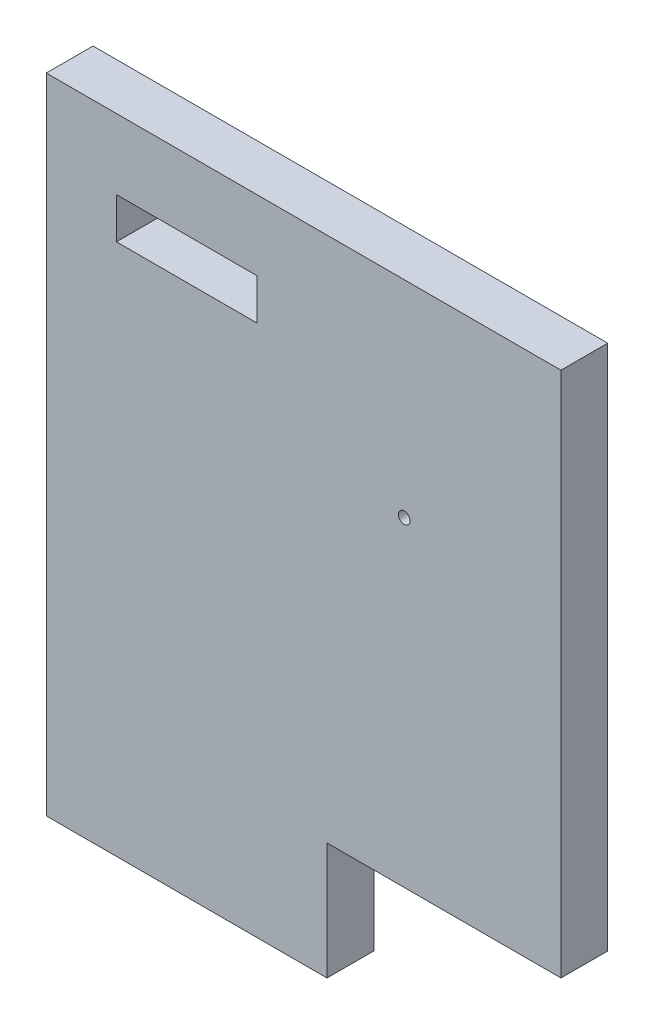
from build123d import *

# Parameters (mm, degrees)
SKIZZE1_W                       = 24
SKIZZE1_H                       = 55
SKIZZE1_W_2                     = 12
SKIZZE1_H_2                     = 3.5
AUFSATZ_LINEAR_AUSTRAGEN1_DEPTH = 4
SKIZZE3_W                       = 20
SKIZZE3_H                       = 45
AUFSATZ_LINEAR_AUSTRAGEN3_DEPTH = 4
SCHNITT_LINEAR_AUSTRAGEN1_REACH = 6
SKIZZE4_R                       = 0.5


with BuildPart() as part:
    # Skizze1 → Aufsatz-Linear austragen1 (new body)
    with BuildSketch(Plane.XY):
        with Locations((12, 27.5)):
            Rectangle(SKIZZE1_W, SKIZZE1_H)
        with Locations((12, 47.25)):
            Rectangle(SKIZZE1_W_2, SKIZZE1_H_2, mode=Mode.SUBTRACT)
    extrude(amount=AUFSATZ_LINEAR_AUSTRAGEN1_DEPTH)

    # Skizze3 → Aufsatz-Linear austragen3 (add)
    with BuildSketch(Plane.XY.offset(4)):
        with Locations((34, 32.5)):
            Rectangle(SKIZZE3_W, SKIZZE3_H)
    extrude(amount=-AUFSATZ_LINEAR_AUSTRAGEN3_DEPTH)

    # Skizze4 → Schnitt-Linear austragen1 (cut, up to next)
    with BuildSketch(Plane.XY.offset(4), mode=Mode.PRIVATE) as schnitt_linear_austragen1_sk1:
        with Locations((30.6, 37.377592673)):
            Circle(SKIZZE4_R)
    schnitt_linear_austragen1_tool1 = extrude(schnitt_linear_austragen1_sk1.sketch, amount=-SCHNITT_LINEAR_AUSTRAGEN1_REACH, mode=Mode.PRIVATE) & part.part
    add(schnitt_linear_austragen1_tool1.solids().sort_by_distance((30.6, 37.377593, 4))[0], mode=Mode.SUBTRACT)


solid = part.part
